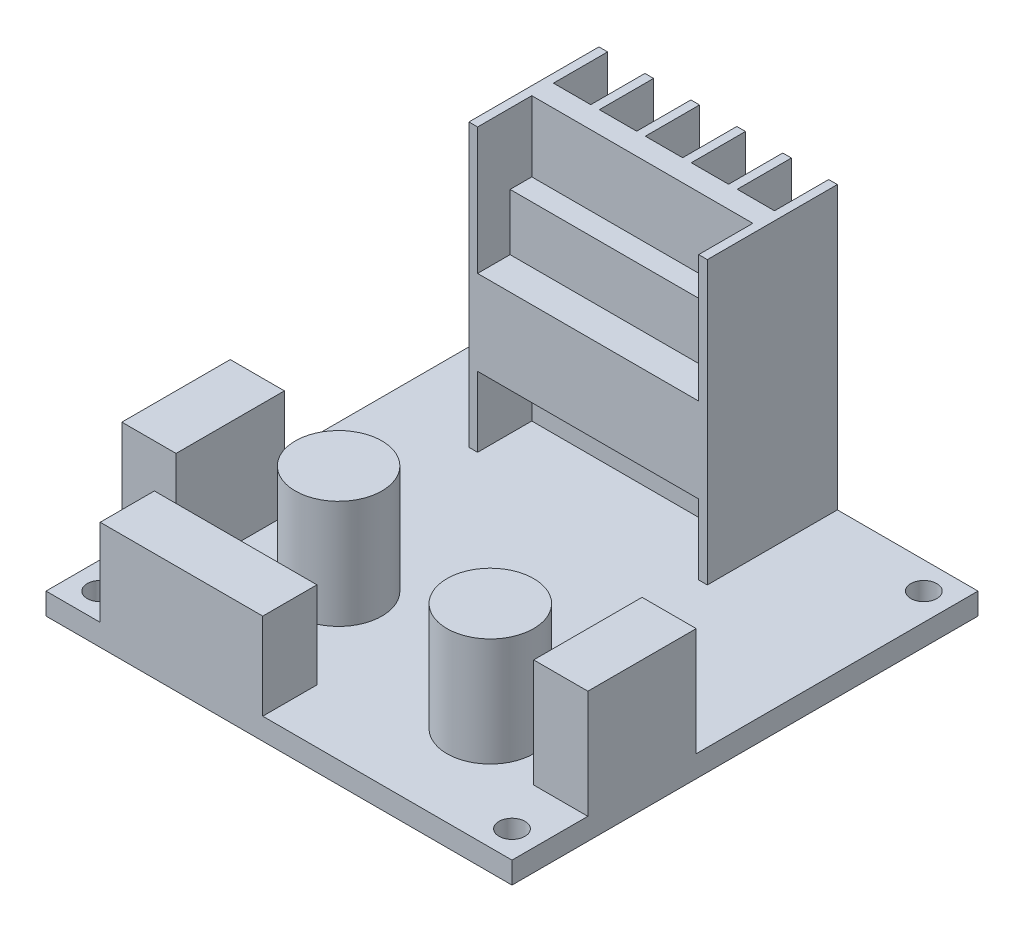
from build123d import *

# Parameters (mm, degrees)
SKETCH_1_W          = 43
SKETCH_1_H          = 43
EXTRUDE_1_DEPTH     = 2
SKETCH_2_W          = 15
SKETCH_2_H          = 5
EXTRUDE_2_DEPTH     = 10
SKETCH_3_W          = 5
SKETCH_3_H          = 10
EXTRUDE_3_DEPTH     = 10
SKETCH_4_W          = 5
SKETCH_4_H          = 10
EXTRUDE_4_DEPTH     = 10
SKETCH_5_R          = 4
EXTRUDE_5_DEPTH     = 10
SKETCH_6_R          = 4
EXTRUDE_6_DEPTH     = 10
SKETCH_7_W          = 22
SKETCH_7_H          = 12
EXTRUDE_7_DEPTH     = 26
SKETCH_8_W          = 3.44
SKETCH_8_H          = 26
SKETCH_8_H_2        = 26.05521278
CUT_EXTRUDE_1_DEPTH = 5
SKETCH_11_W         = 20.4
SKETCH_11_H         = 26
CUT_EXTRUDE_2_DEPTH = 5
SKETCH_12_W         = 20.4
SKETCH_12_H         = 7.82225214
EXTRUDE_8_DEPTH     = 5
SKETCH_13_W         = 20.4
SKETCH_13_H         = 5.214716639
EXTRUDE_9_DEPTH     = 2
SKETCH_14_R         = 1.2
CUT_EXTRUDE_3_DEPTH = 2


with BuildPart() as part:
    # 草图1 → 凸台-拉伸1 (new body)
    with BuildSketch(Plane(origin=(0, 0, 0), x_dir=(1, 0, 0), z_dir=(0, 1, 0))):
        Rectangle(SKETCH_1_W, SKETCH_1_H)
    extrude(amount=EXTRUDE_1_DEPTH)

    # 草图2 → 凸台-拉伸2 (add)
    with BuildSketch(Plane(origin=(0, 0, 0), x_dir=(1, 0, 0), z_dir=(0, 1, 0))):
        with Locations((-9, -19)):
            Rectangle(SKETCH_2_W, SKETCH_2_H)
    extrude(amount=EXTRUDE_2_DEPTH)

    # 草图3 → 凸台-拉伸3 (add)
    with BuildSketch(Plane(origin=(0, 2, 0), x_dir=(1, 0, 0), z_dir=(0, 1, 0))):
        with Locations((-19, -9.5)):
            Rectangle(SKETCH_3_W, SKETCH_3_H)
    extrude(amount=EXTRUDE_3_DEPTH)

    # 草图4 → 凸台-拉伸4 (add)
    with BuildSketch(Plane(origin=(0, 2, 0), x_dir=(1, 0, 0), z_dir=(0, 1, 0))):
        with Locations((19, -9.5)):
            Rectangle(SKETCH_4_W, SKETCH_4_H)
    extrude(amount=EXTRUDE_4_DEPTH)

    # 草图5 → 凸台-拉伸5 (add)
    with BuildSketch(Plane(origin=(0, 2, 0), x_dir=(1, 0, 0), z_dir=(0, 1, 0))):
        with Locations((-8, -8)):
            Circle(SKETCH_5_R)
    extrude(amount=EXTRUDE_5_DEPTH)

    # 草图6 → 凸台-拉伸6 (add)
    with BuildSketch(Plane(origin=(0, 2, 0), x_dir=(1, 0, 0), z_dir=(0, 1, 0))):
        with Locations((10, -12)):
            Circle(SKETCH_6_R)
    extrude(amount=EXTRUDE_6_DEPTH)

    # 草图7 → 凸台-拉伸7 (add)
    with BuildSketch(Plane(origin=(0, 2, 0), x_dir=(1, 0, 0), z_dir=(0, 1, 0))):
        with Locations((-2.475742283, 15.5)):
            Rectangle(SKETCH_7_W, SKETCH_7_H)
    extrude(amount=EXTRUDE_7_DEPTH)

    # 草图8 → 切除-拉伸1 (cut)
    with BuildSketch(Plane(origin=(0, 0, -21.5), x_dir=(-1, 0, 0), z_dir=(0, 0, -1))):
        with Locations((10.955742283, 15)):
            Rectangle(SKETCH_8_W, SKETCH_8_H)
        with Locations((6.715742283, 14.97239361)):
            Rectangle(SKETCH_8_W, SKETCH_8_H_2)
        with Locations((2.475742283, 15)):
            Rectangle(SKETCH_8_W, SKETCH_8_H)
        with Locations((-1.764257717, 15)):
            Rectangle(SKETCH_8_W, SKETCH_8_H)
        with Locations((-6.004257717, 15)):
            Rectangle(SKETCH_8_W, SKETCH_8_H)
    extrude(amount=-CUT_EXTRUDE_1_DEPTH, mode=Mode.SUBTRACT)

    # 草图11 → 切除-拉伸2 (cut)
    with BuildSketch(Plane.XY.offset(-9.5)):
        with Locations((-2.475742283, 15)):
            Rectangle(SKETCH_11_W, SKETCH_11_H)
    extrude(amount=-CUT_EXTRUDE_2_DEPTH, mode=Mode.SUBTRACT)

    # 草图12 → 凸台-拉伸8 (add)
    with BuildSketch(Plane.XY.offset(-14.5)):
        with Locations((-2.475742283, 12.38380745)):
            Rectangle(SKETCH_12_W, SKETCH_12_H)
    extrude(amount=EXTRUDE_8_DEPTH)

    # 草图13 → 凸台-拉伸9 (add)
    with BuildSketch(Plane.XY.offset(-14.5)):
        with Locations((-2.475742283, 18.90229184)):
            Rectangle(SKETCH_13_W, SKETCH_13_H)
    extrude(amount=EXTRUDE_9_DEPTH)

    # 草图14 → 切除-拉伸3 (cut)
    with BuildSketch(Plane(origin=(0, 2, 0), x_dir=(1, 0, 0), z_dir=(0, 1, 0))):
        with Locations((-19, 19)):
            Circle(SKETCH_14_R)
        with Locations((19, 19)):
            Circle(SKETCH_14_R)
        with Locations((-19, -19)):
            Circle(SKETCH_14_R)
        with Locations((19, -19)):
            Circle(SKETCH_14_R)
    extrude(amount=-CUT_EXTRUDE_3_DEPTH, mode=Mode.SUBTRACT)


solid = part.part
